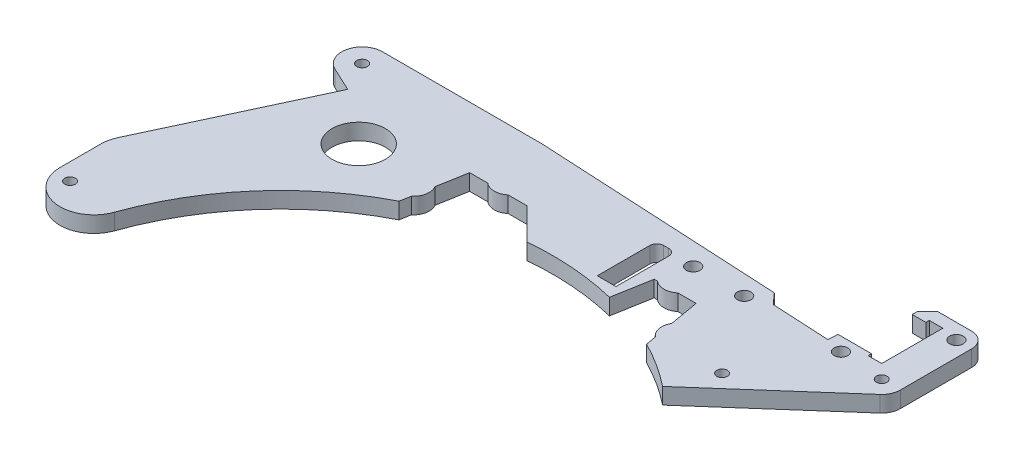
from build123d import *

# Parameters (mm, degrees)
SKETCH1_R           = 7.85
SKETCH1_R_2         = 1.5625
SKETCH1_R_3         = 2
BOSS_EXTRUDE1_DEPTH = 4.7625
BOSS_EXTRUDE2_DEPTH = 4.7625
SKETCH4_R           = 2
SKETCH4_W           = 5.5
SKETCH4_H           = 17.5
CUT_EXTRUDE1_DEPTH  = 5.7625
CHAMFER1_SIZE       = 3
FILLET1_R           = 4.5
FILLET2_R           = 2


with BuildPart() as part:
    # Sketch1 → Boss-Extrude1 (new body)
    with BuildSketch(Plane(origin=(0, 0, 0), x_dir=(1, 0, 0), z_dir=(0, 1, 0))):
        with BuildLine():
            Line((-36.456035166, 71.322980167), (-35.908059548, 74.43070433))
            ThreePointArc((-35.908059548, 74.43070433), (-34.303826486, 77.194114594), (-34.866170482, 80.339550848))
            Line((-34.866170482, 80.339550848), (-33.339099631, 89))
            Line((-33.339099631, 89), (-28, 89))
            ThreePointArc((-28, 89), (-25, 87.9), (-22, 89))
            Line((-22, 89), (-16.5, 89))
            Line((-16.5, 89), (-7.269449675, 79.769449675))
            ThreePointArc((-7.269449675, 79.769449675), (0, 80.1), (7.269449675, 79.769449675))
            Line((7.269449675, 79.769449675), (16.5, 89))
            Line((16.5, 89), (22, 89))
            ThreePointArc((22, 89), (25, 87.9), (28, 89))
            Line((28, 89), (33.339099631, 89))
            Line((33.339099631, 89), (34.866170482, 80.339550848))
            ThreePointArc((34.866170482, 80.339550848), (34.303826486, 77.194114594), (35.908059548, 74.43070433))
            Line((35.908059548, 74.43070433), (36.456035166, 71.322980167))
            ThreePointArc((36.456035166, 71.322980167), (43.225467457, 67.435665364), (49.584363344, 62.907876389))
            Line((49.584363344, 62.907876389), (83.633453422, 92.871075657))
            ThreePointArc((83.633453422, 92.871075657), (85.011686035, 94.734386818), (85.5, 97))
            Line((85.5, 97), (85.5, 122.5))
            Line((85.5, 122.5), (68, 122.5))
            Line((68, 122.5), (68, 118))
            Line((68, 118), (72, 118))
            Line((72, 118), (72, 119))
            Line((72, 119), (76, 119))
            Line((76, 119), (76, 101))
            Line((76, 101), (72, 101))
            Line((72, 101), (72, 102))
            Line((72, 102), (62.124723238, 102))
            Line((62.124723238, 102), (61.976702091, 99.17558826))
            Line((61.976702091, 99.17558826), (45, 100.065299516))
            Line((45, 100.065299516), (42.161119264, 103.218195989))
            Line((42.161119264, 103.218195989), (-30, 107))
            Line((-30, 107), (-77, 107))
            ThreePointArc((-77, 107), (-82.857776043, 102.298637684), (-79.53570957, 95.562153278))
            Line((-79.53570957, 95.562153278), (-72.537844854, 92.29899537))
            Line((-72.537844854, 92.29899537), (-94.021950273, 46.226182617))
            ThreePointArc((-94.021950273, 46.226182617), (-94.721832474, 44.164396139), (-94.958872403, 42))
            Line((-94.958872403, 42), (-94.958872403, 30))
            ThreePointArc((-94.958872403, 30), (-86.647958542, 20.143682837), (-75.5294748, 26.67036626))
            ThreePointArc((-75.5294748, 26.67036626), (-60.279785939, 52.748055957), (-36.456035166, 71.322980167))
        make_face()
        with Locations((-57, 80)):
            Circle(SKETCH1_R, mode=Mode.SUBTRACT)
        with Locations((80, 97)):
            Circle(SKETCH1_R_2, mode=Mode.SUBTRACT)
        with Locations((-90, 28)):
            Circle(SKETCH1_R_2, mode=Mode.SUBTRACT)
        with Locations((-77, 101)):
            Circle(SKETCH1_R_2, mode=Mode.SUBTRACT)
        with Locations((81, 118)):
            Circle(SKETCH1_R_3, mode=Mode.SUBTRACT)
        with Locations((67, 98)):
            Circle(SKETCH1_R_3, mode=Mode.SUBTRACT)
        with Locations((55, 75)):
            Circle(SKETCH1_R_2, mode=Mode.SUBTRACT)
    extrude(amount=BOSS_EXTRUDE1_DEPTH)

    # Sketch2 → Boss-Extrude2 (add)
    with BuildSketch(Plane(origin=(0, 4.7625, 0), x_dir=(1, 0, 0), z_dir=(0, 1, 0))):
        with BuildLine():
            Line((19.026456742, 77.807479999), (21, 89))
            Line((21, 89), (16.5, 89))
            Line((16.5, 89), (7.269449675, 79.769449675))
            ThreePointArc((7.269449675, 79.769449675), (13.184498656, 79.007461642), (19.026456742, 77.807479999))
        make_face()
    extrude(amount=-BOSS_EXTRUDE2_DEPTH)

    # Sketch4 → Cut-Extrude1 (cut, through all)
    with BuildSketch(Plane(origin=(0, 4.7625, 0), x_dir=(1, 0, 0), z_dir=(0, 1, 0))):
        with Locations((23.5, 98)):
            Circle(SKETCH4_R)
        with Locations((38.5, 98)):
            Circle(SKETCH4_R)
        with Locations((14.5, 90.25)):
            Rectangle(SKETCH4_W, SKETCH4_H)
    extrude(amount=-CUT_EXTRUDE1_DEPTH, mode=Mode.SUBTRACT)

    # Chamfer1
    chamfer1_edges = [part.edges().sort_by_distance(p)[0] for p in [
        (68, 2.38125, -122.5),
    ]]
    chamfer(chamfer1_edges, length=CHAMFER1_SIZE)

    # Fillet1
    fillet1_edges = [part.edges().sort_by_distance(p)[0] for p in [
        (85.5, 2.38125, -122.5),
    ]]
    fillet(fillet1_edges, radius=FILLET1_R)

    # Fillet2
    fillet2_edges = [part.edges().sort_by_distance(p)[0] for p in [
        (17.25, 2.38125, -99),
        (11.75, 2.38125, -99),
    ]]
    fillet(fillet2_edges, radius=FILLET2_R)


solid = part.part
